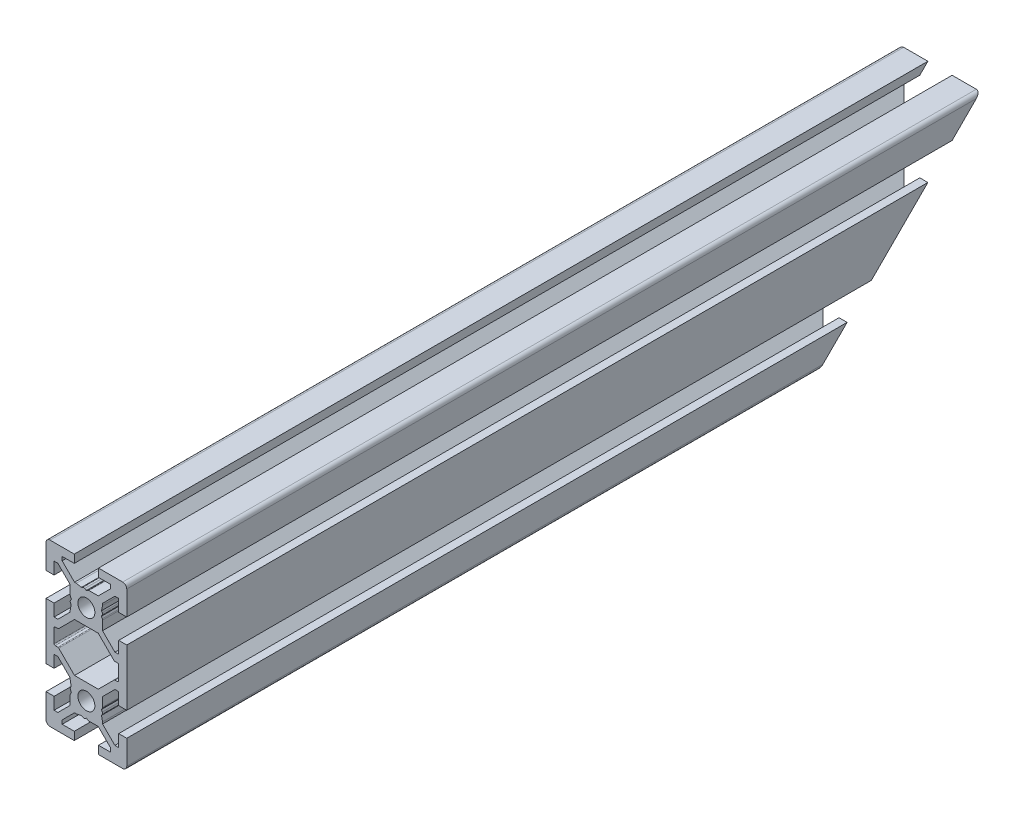
from build123d import *

# Parameters (mm, degrees)
SKETCH1_R           = 2.1
BOSS_EXTRUDE1_DEPTH = 211.39
CUT_EXTRUDE1_DEPTH  = 21


with BuildPart() as part:
    # Sketch1 → Boss-Extrude1 (new body)
    with BuildSketch(Plane(origin=(0, 0, -600), x_dir=(-1, 0, 0), z_dir=(0, 0, -1))):
        with BuildLine():
            Line((10, -7), (10, 7))
            Line((10, 7), (8, 7))
            Line((8, 7), (8, 4))
            Line((8, 4), (7.060660172, 4))
            Line((7.060660172, 4), (4, 7.060660172))
            Line((4, 7.060660172), (4, 7.5))
            Line((4, 7.5), (3.750976592, 8.781114371))
            Line((3.750976592, 8.781114371), (3.933012702, 9.096410162))
            ThreePointArc((3.933012702, 9.096410162), (4, 9.346410162), (3.933012702, 9.596410162))
            Line((3.933012702, 9.596410162), (3.7, 10))
            Line((3.7, 10), (3.933012702, 10.403589838))
            ThreePointArc((3.933012702, 10.403589838), (3.982962913, 10.524180316), (4, 10.653589838))
            Line((4, 10.653589838), (4, 12.939339828))
            Line((4, 12.939339828), (7.060660172, 16))
            Line((7.060660172, 16), (8, 16))
            Line((8, 16), (8, 13))
            Line((8, 13), (10, 13))
            Line((10, 13), (10, 19))
            ThreePointArc((10, 19), (9.707106781, 19.707106781), (9, 20))
            Line((9, 20), (3, 20))
            Line((3, 20), (3, 18))
            Line((3, 18), (6, 18))
            Line((6, 18), (6, 17.060660172))
            Line((6, 17.060660172), (2.939339828, 14))
            Line((2.939339828, 14), (2.5, 14))
            Line((2.5, 14), (1.218885629, 13.750976592))
            Line((1.218885629, 13.750976592), (0.903589838, 13.933012702))
            ThreePointArc((0.903589838, 13.933012702), (0.653589838, 14), (0.403589838, 13.933012702))
            Line((0.403589838, 13.933012702), (0, 13.7))
            Line((0, 13.7), (-0.403589838, 13.933012702))
            ThreePointArc((-0.403589838, 13.933012702), (-0.524180316, 13.982962913), (-0.653589838, 14))
            Line((-0.653589838, 14), (-2.939339828, 14))
            Line((-2.939339828, 14), (-6, 17.060660172))
            Line((-6, 17.060660172), (-6, 18))
            Line((-6, 18), (-3, 18))
            Line((-3, 18), (-3, 20))
            Line((-3, 20), (-9, 20))
            ThreePointArc((-9, 20), (-9.707106781, 19.707106781), (-10, 19))
            Line((-10, 19), (-10, 13))
            Line((-10, 13), (-8, 13))
            Line((-8, 13), (-8, 16))
            Line((-8, 16), (-7.060660172, 16))
            Line((-7.060660172, 16), (-4, 12.939339828))
            Line((-4, 12.939339828), (-4, 12.5))
            Line((-4, 12.5), (-3.750976592, 11.218885629))
            Line((-3.750976592, 11.218885629), (-3.933012702, 10.903589838))
            ThreePointArc((-3.933012702, 10.903589838), (-4, 10.653589838), (-3.933012702, 10.403589838))
            Line((-3.933012702, 10.403589838), (-3.7, 10))
            Line((-3.7, 10), (-3.933012702, 9.596410162))
            ThreePointArc((-3.933012702, 9.596410162), (-3.982962913, 9.475819684), (-4, 9.346410162))
            Line((-4, 9.346410162), (-4, 7.060660172))
            Line((-4, 7.060660172), (-7.060660172, 4))
            Line((-7.060660172, 4), (-8, 4))
            Line((-8, 4), (-8, 7))
            Line((-8, 7), (-10, 7))
            Line((-10, 7), (-10, -7))
            Line((-10, -7), (-8, -7))
            Line((-8, -7), (-8, -4))
            Line((-8, -4), (-7.060660172, -4))
            Line((-7.060660172, -4), (-4, -7.060660172))
            Line((-4, -7.060660172), (-4, -9.346410162))
            ThreePointArc((-4, -9.346410162), (-3.982962913, -9.475819684), (-3.933012702, -9.596410162))
            Line((-3.933012702, -9.596410162), (-3.7, -10))
            Line((-3.7, -10), (-3.933012702, -10.403589838))
            ThreePointArc((-3.933012702, -10.403589838), (-4, -10.653589838), (-3.933012702, -10.903589838))
            Line((-3.933012702, -10.903589838), (-3.750976592, -11.218885629))
            Line((-3.750976592, -11.218885629), (-4, -12.5))
            Line((-4, -12.5), (-4, -12.939339828))
            Line((-4, -12.939339828), (-7.060660172, -16))
            Line((-7.060660172, -16), (-8, -16))
            Line((-8, -16), (-8, -13))
            Line((-8, -13), (-10, -13))
            Line((-10, -13), (-10, -19))
            ThreePointArc((-10, -19), (-9.707106781, -19.707106781), (-9, -20))
            Line((-9, -20), (-3, -20))
            Line((-3, -20), (-3, -18))
            Line((-3, -18), (-6, -18))
            Line((-6, -18), (-6, -17.060660172))
            Line((-6, -17.060660172), (-2.939339828, -14))
            Line((-2.939339828, -14), (-0.653589838, -14))
            ThreePointArc((-0.653589838, -14), (-0.524180316, -13.982962913), (-0.403589838, -13.933012702))
            Line((-0.403589838, -13.933012702), (0, -13.7))
            Line((0, -13.7), (0.403589839, -13.933012702))
            ThreePointArc((0.403589839, -13.933012702), (0.653589839, -14), (0.903589838, -13.933012702))
            Line((0.903589838, -13.933012702), (1.218885629, -13.750976592))
            Line((1.218885629, -13.750976592), (2.5, -14))
            Line((2.5, -14), (2.939339828, -14))
            Line((2.939339828, -14), (6, -17.060660172))
            Line((6, -17.060660172), (6, -18))
            Line((6, -18), (3, -18))
            Line((3, -18), (3, -20))
            Line((3, -20), (9, -20))
            ThreePointArc((9, -20), (9.707106781, -19.707106781), (10, -19))
            Line((10, -19), (10, -13))
            Line((10, -13), (8, -13))
            Line((8, -13), (8, -16))
            Line((8, -16), (7.060660172, -16))
            Line((7.060660172, -16), (4, -12.939339828))
            Line((4, -12.939339828), (4, -10.653589838))
            ThreePointArc((4, -10.653589838), (3.982962913, -10.524180316), (3.933012702, -10.403589838))
            Line((3.933012702, -10.403589838), (3.7, -10))
            Line((3.7, -10), (3.933012702, -9.596410162))
            ThreePointArc((3.933012702, -9.596410162), (4, -9.346410162), (3.933012702, -9.096410162))
            Line((3.933012702, -9.096410162), (3.750976592, -8.781114371))
            Line((3.750976592, -8.781114371), (4, -7.5))
            Line((4, -7.5), (4, -7.060660172))
            Line((4, -7.060660172), (7.060660172, -4))
            Line((7.060660172, -4), (8, -4))
            Line((8, -4), (8, -7))
            Line((8, -7), (10, -7))
        make_face()
        with Locations((0, -10)):
            Circle(SKETCH1_R, mode=Mode.SUBTRACT)
        with Locations((0, 10)):
            Circle(SKETCH1_R, mode=Mode.SUBTRACT)
        with BuildLine():
            Line((8, 1.7), (8, -1.7))
            ThreePointArc((8, -1.7), (7.912132034, -1.912132034), (7.7, -2))
            Line((7.7, -2), (7.063603897, -2))
            ThreePointArc((7.063603897, -2), (6.948798867, -2.02283614), (6.851471863, -2.087867966))
            Line((6.851471863, -2.087867966), (2.939339828, -6))
            Line((2.939339828, -6), (-2.939339828, -6))
            Line((-2.939339828, -6), (-6.851471863, -2.087867966))
            ThreePointArc((-6.851471863, -2.087867966), (-6.948798867, -2.02283614), (-7.063603897, -2))
            Line((-7.063603897, -2), (-7.7, -2))
            ThreePointArc((-7.7, -2), (-7.912132034, -1.912132034), (-8, -1.7))
            Line((-8, -1.7), (-8, 1.7))
            ThreePointArc((-8, 1.7), (-7.912132034, 1.912132034), (-7.7, 2))
            Line((-7.7, 2), (-7.063603897, 2))
            ThreePointArc((-7.063603897, 2), (-6.948798867, 2.02283614), (-6.851471863, 2.087867966))
            Line((-6.851471863, 2.087867966), (-2.939339828, 6))
            Line((-2.939339828, 6), (2.939339828, 6))
            Line((2.939339828, 6), (6.851471863, 2.087867966))
            ThreePointArc((6.851471863, 2.087867966), (6.948798867, 2.02283614), (7.063603897, 2))
            Line((7.063603897, 2), (7.7, 2))
            ThreePointArc((7.7, 2), (7.912132034, 1.912132034), (8, 1.7))
        make_face(mode=Mode.SUBTRACT)
    extrude(amount=-BOSS_EXTRUDE1_DEPTH)

    # Sketch2 → Cut-Extrude1 (cut, through all)
    with BuildSketch(Plane.ZY.offset(10)):
        Polygon((-600, 20), (-560, -20), (-600, -20), align=None)
    extrude(amount=-CUT_EXTRUDE1_DEPTH, mode=Mode.SUBTRACT)


solid = part.part
